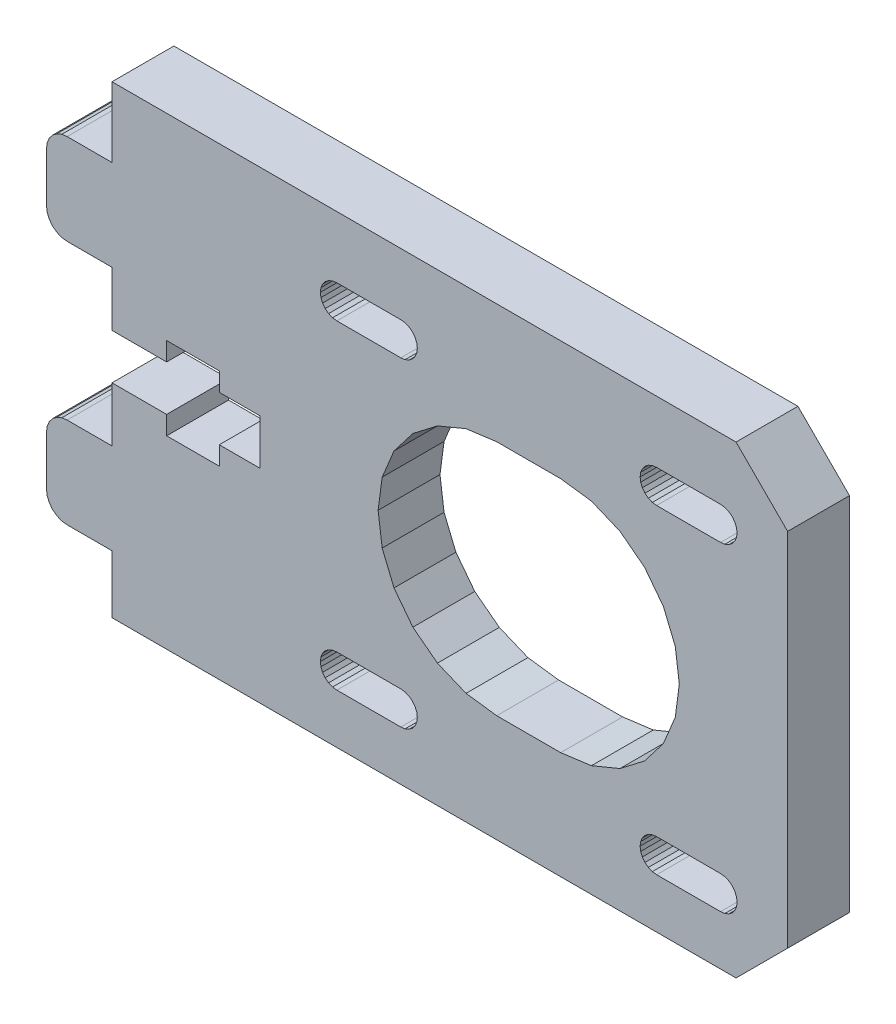
from build123d import *

# Parameters (mm, degrees)
BOSS_EXTRUDE1_DEPTH = 6


with BuildPart() as part:
    # Sketch1 → Boss-Extrude1 (new body)
    with BuildSketch(Plane.XY):
        Polygon((-107.062987014, -155.556624264), (-112.062985414, -150.556625864), (-172.562973402, -150.556625864), (-172.562973402, -157.335700029), (-176.912971293, -157.335700029), (-177.430609383, -157.403848376), (-177.912971293, -157.603649221), (-178.327184855, -157.921486467), (-178.6450221, -158.335700029), (-178.844822945, -158.818061939), (-178.912971293, -159.335700029), (-178.912971293, -164.135695994), (-178.844822945, -164.653334084), (-178.6450221, -165.135695994), (-178.327184855, -165.549909556), (-177.912971293, -165.867746802), (-177.430609383, -166.067547647), (-176.912971293, -166.135695994), (-172.562973402, -166.135695994), (-172.562973402, -171.435688001), (-167.26297458, -171.435688001), (-167.26297458, -169.635689769), (-162.162976815, -169.635689769), (-162.162976815, -171.435688001), (-158.212977143, -171.435688001), (-158.212977143, -175.835692673), (-162.162976966, -175.835692673), (-162.162976966, -177.635690904), (-167.26297473, -177.635690904), (-167.26297473, -175.835692673), (-172.562973552, -175.835692673), (-172.562973552, -181.135689927), (-176.912971443, -181.135689927), (-177.430609533, -181.203838275), (-177.912971443, -181.40363912), (-178.327185006, -181.721476365), (-178.645022251, -182.135689927), (-178.844823096, -182.618051837), (-178.912971443, -183.135689927), (-178.912971443, -187.93568437), (-178.844823096, -188.45332246), (-178.645022251, -188.93568437), (-178.327185006, -189.349897932), (-177.912971443, -189.667735177), (-177.430609533, -189.867536022), (-176.912971443, -189.93568437), (-172.562973552, -189.93568437), (-172.562973552, -195.556608264), (-112.062985371, -195.556608264), (-107.062987014, -190.556608264), align=None)
        Polygon((-150.762975594, -156.535695809), (-151.177085934, -156.590214469), (-151.562975338, -156.750055094), (-151.894346082, -157.004324809), (-152.148615797, -157.335695553), (-152.308456422, -157.721584957), (-152.362975082, -158.135695297), (-152.308456422, -158.549805636), (-152.148615797, -158.935695041), (-151.894346082, -159.267065785), (-151.562975338, -159.521335499), (-151.177085934, -159.681176124), (-150.762975594, -159.735694785), (-144.562976618, -159.735694785), (-144.148866278, -159.681176124), (-143.762976874, -159.521335499), (-143.43160613, -159.267065785), (-143.177336415, -158.935695041), (-143.017495791, -158.549805636), (-142.96297713, -158.135695297), (-143.017495791, -157.721584957), (-143.177336415, -157.335695553), (-143.43160613, -157.004324809), (-143.762976874, -156.750055094), (-144.148866278, -156.590214469), (-144.562976618, -156.535695809), align=None, mode=Mode.SUBTRACT)
        Polygon((-143.431606507, -188.004315269), (-143.762977251, -187.750045554), (-144.148866655, -187.590204929), (-144.562976995, -187.535686269), (-150.762975971, -187.535686269), (-151.17708631, -187.590204929), (-151.562975715, -187.750045554), (-151.894346459, -188.004315269), (-152.148616173, -188.335686013), (-152.308456798, -188.721575417), (-152.362975459, -189.135685757), (-152.308456798, -189.549796096), (-152.148616173, -189.935685501), (-151.894346459, -190.267056245), (-151.562975715, -190.521325959), (-151.17708631, -190.681166584), (-150.762975971, -190.735685245), (-144.562976995, -190.735685245), (-144.148866655, -190.681166584), (-143.762977251, -190.521325959), (-143.431606507, -190.267056245), (-143.177336792, -189.935685501), (-143.017496167, -189.549796096), (-142.962977507, -189.135685757), (-143.017496167, -188.721575417), (-143.177336792, -188.335686013), align=None, mode=Mode.SUBTRACT)
        Polygon((-121.362985002, -189.135685377), (-121.308466342, -189.549795716), (-121.148625717, -189.935685121), (-120.894356002, -190.267055865), (-120.562985258, -190.521325579), (-120.177095854, -190.681166204), (-119.762985514, -190.735684865), (-113.562986538, -190.735684865), (-113.148876198, -190.681166204), (-112.762986794, -190.521325579), (-112.43161605, -190.267055865), (-112.177346335, -189.935685121), (-112.017505711, -189.549795716), (-111.96298705, -189.135685377), (-112.017505711, -188.721575037), (-112.177346335, -188.335685633), (-112.43161605, -188.004314889), (-112.762986794, -187.750045174), (-113.148876198, -187.590204549), (-113.562986538, -187.535685889), (-119.762985514, -187.535685889), (-120.177095854, -187.590204549), (-120.562985258, -187.750045174), (-120.894356002, -188.004314889), (-121.148625717, -188.335685633), (-121.308466342, -188.721575037), align=None, mode=Mode.SUBTRACT)
        Polygon((-119.762985514, -156.535695809), (-113.562986538, -156.535695809), (-113.148876198, -156.590214469), (-112.762986794, -156.750055094), (-112.43161605, -157.004324809), (-112.177346335, -157.335695553), (-112.017505711, -157.721584957), (-111.96298705, -158.135695297), (-112.017505711, -158.549805636), (-112.177346335, -158.935695041), (-112.43161605, -159.267065785), (-112.762986794, -159.521335499), (-113.148876198, -159.681176124), (-113.562986538, -159.735694785), (-119.762985514, -159.735694785), (-120.177095854, -159.681176124), (-120.562985258, -159.521335499), (-120.894356002, -159.267065785), (-121.148625717, -158.935695041), (-121.308466342, -158.549805636), (-121.362985002, -158.135695297), (-121.308466342, -157.721584957), (-121.148625717, -157.335695553), (-120.894356002, -157.004324809), (-120.562985258, -156.750055094), (-120.177095854, -156.590214469), align=None, mode=Mode.SUBTRACT)
        Polygon((-126.086563512, -184.743833784), (-123.312983418, -183.594979293), (-120.931256197, -181.767415718), (-119.103692622, -179.385688497), (-117.95483813, -176.612108403), (-117.562985258, -173.635690337), (-117.95483813, -170.65927227), (-119.103692622, -167.885692177), (-120.931256197, -165.503964955), (-123.312983418, -163.67640138), (-126.086563512, -162.527546889), (-129.062981578, -162.135694017), (-135.262980554, -162.135694017), (-138.23939862, -162.527546889), (-141.012978714, -163.67640138), (-143.394705936, -165.503964955), (-145.222269511, -167.885692177), (-146.371124002, -170.65927227), (-146.762976874, -173.635690337), (-146.371124002, -176.612108403), (-145.222269511, -179.385688497), (-143.394705936, -181.767415718), (-141.012978714, -183.594979293), (-138.23939862, -184.743833784), (-135.262980554, -185.135686657), (-129.062981578, -185.135686657), align=None, mode=Mode.SUBTRACT)
    extrude(amount=BOSS_EXTRUDE1_DEPTH)


solid = part.part
